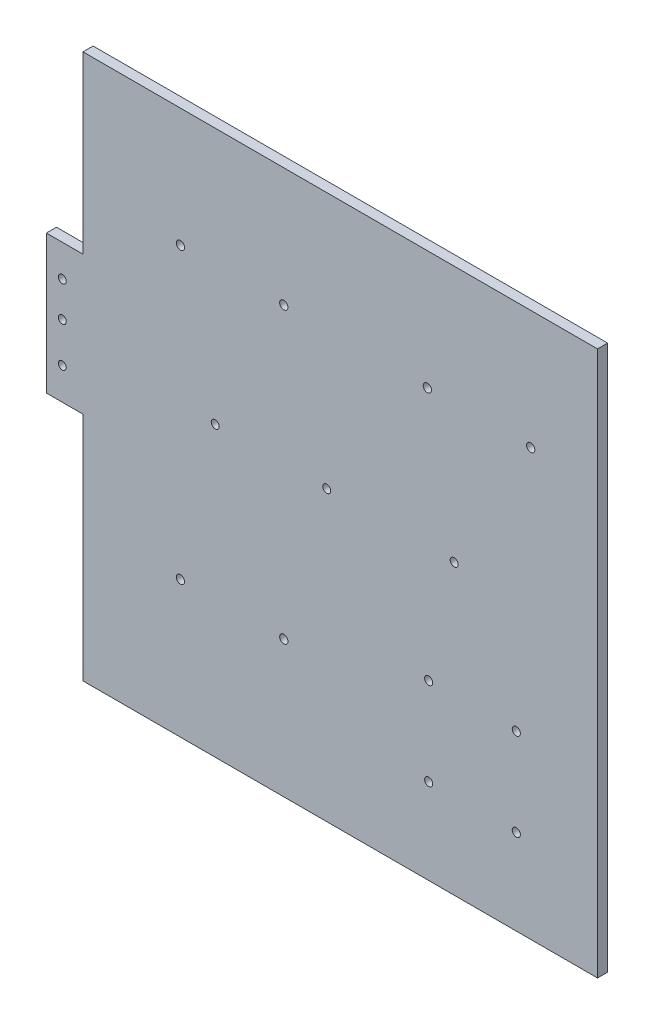
from build123d import *

# Parameters (mm, degrees)
MODEL_R             = 2.5
MODEL_R_2           = 2.6
MODEL_R_3           = 2.55
BOSS_EXTRUDE1_DEPTH = 6.35


with BuildPart() as part:
    # Model → Boss-Extrude1 (new body)
    with BuildSketch(Plane.XY):
        Polygon((691.840616937, 302.611489719), (368.840616937, 302.611489719), (368.840616937, 447.611489719), (345.840616937, 447.611489719), (345.840616937, 534.611489719), (368.840616937, 534.611489719), (368.840616937, 644.611489719), (691.840616937, 644.611489719), align=None)
        with Locations((355.840616937, 514.611489719)):
            Circle(MODEL_R, mode=Mode.SUBTRACT)
        with Locations((355.840616937, 492.611489719)):
            Circle(MODEL_R, mode=Mode.SUBTRACT)
        with Locations((355.840616937, 467.611489719)):
            Circle(MODEL_R, mode=Mode.SUBTRACT)
        with Locations((430, 570)):
            Circle(MODEL_R_2, mode=Mode.SUBTRACT)
        with Locations((494.9, 570)):
            Circle(MODEL_R_2, mode=Mode.SUBTRACT)
        with Locations((451.840616937, 483.611489719)):
            Circle(MODEL_R, mode=Mode.SUBTRACT)
        with Locations((521.840616937, 483.611489719)):
            Circle(MODEL_R, mode=Mode.SUBTRACT)
        with Locations((601.840616937, 483.611489719)):
            Circle(MODEL_R, mode=Mode.SUBTRACT)
        with Locations((585, 570)):
            Circle(MODEL_R_2, mode=Mode.SUBTRACT)
        with Locations((649.9, 570)):
            Circle(MODEL_R_2, mode=Mode.SUBTRACT)
        with Locations((430, 388.410571956)):
            Circle(MODEL_R_2, mode=Mode.SUBTRACT)
        with Locations((494.9, 388.410571956)):
            Circle(MODEL_R_2, mode=Mode.SUBTRACT)
        with Locations((585.843810025, 411.289923372)):
            Circle(MODEL_R_3, mode=Mode.SUBTRACT)
        with Locations((640.843810025, 411.289923372)):
            Circle(MODEL_R_3, mode=Mode.SUBTRACT)
        with Locations((585.843810025, 356.289923372)):
            Circle(MODEL_R_3, mode=Mode.SUBTRACT)
        with Locations((640.843810025, 356.289923372)):
            Circle(MODEL_R_3, mode=Mode.SUBTRACT)
    extrude(amount=-BOSS_EXTRUDE1_DEPTH)


solid = part.part
